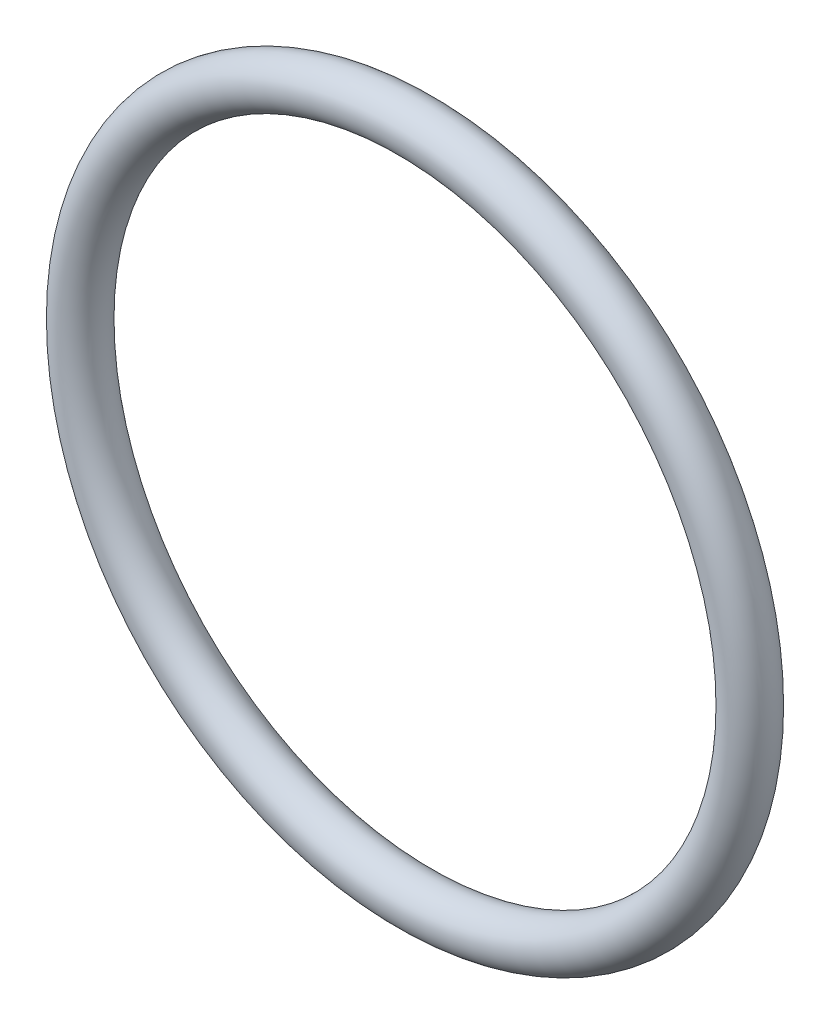
from build123d import *

# Parameters (mm, degrees)
ESQUISSE1_R = 2


with BuildPart() as part:
    # Esquisse1 → Révolution1 (revolve)
    with BuildSketch(Plane(origin=(0, 0, 0), x_dir=(0, 0, -1), z_dir=(1, 0, 0))):
        with Locations((0, 28)):
            Circle(ESQUISSE1_R)
    revolve(axis=Axis((0, 0, -88.99), (0, 0, 1)))


solid = part.part
